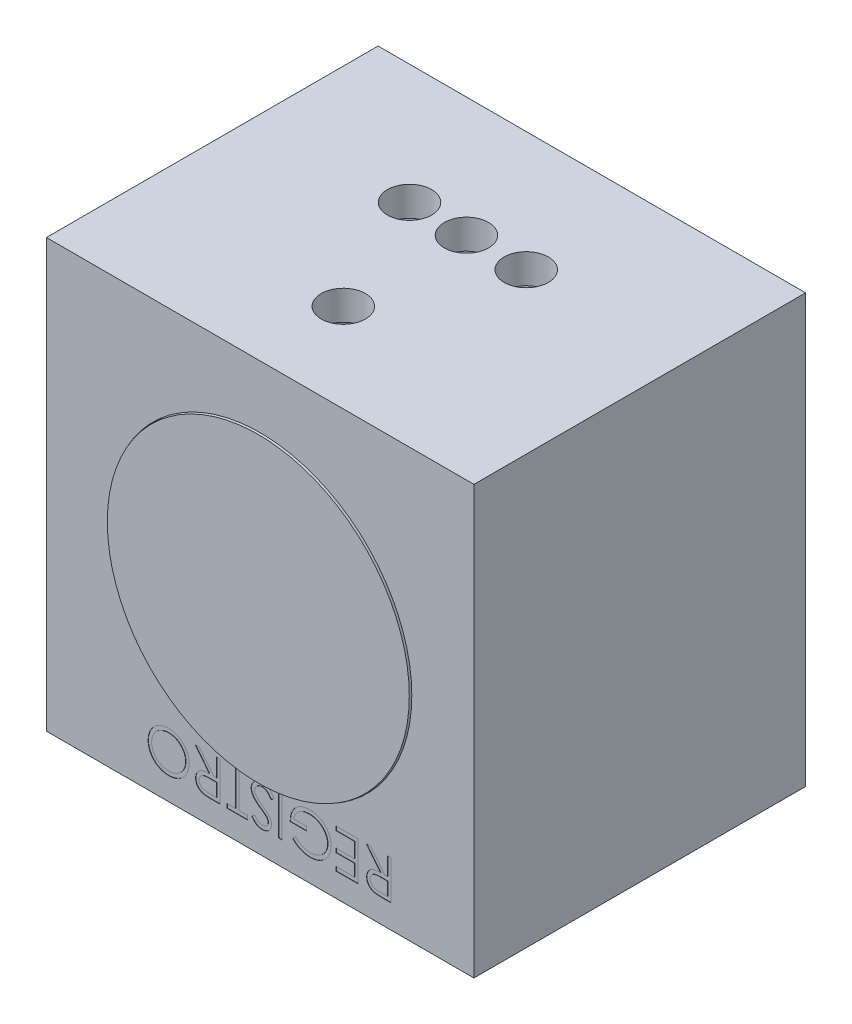
from build123d import *

# Parameters (mm, degrees)
CROQUIS1_W                   = 1160
CROQUIS1_H                   = 1160
CROQUIS1_W_2                 = 1000
CROQUIS1_H_2                 = 1000
SALIENTE_EXTRUIR2_DEPTH      = 900
CROQUIS2_W                   = 1160
CROQUIS2_H                   = 1160
SALIENTE_EXTRUIR3_DEPTH      = 80
CROQUIS5_R                   = 60
CORTAR_EXTRUIR2_DEPTH        = 1160
CROQUIS7_W                   = 1160
CROQUIS7_H                   = 1160
CROQUIS7_R                   = 387.5
SALIENTE_EXTRUIR5_DEPTH      = 100
CROQUIS8_W                   = 9.497863247
CROQUIS8_H                   = 105.833333333
CORTAR_EXTRUIR3_DEPTH        = 1
CROQUIS9_R                   = 411.5
CROQUIS9_R_2                 = 387.5
CORTAR_EXTRUIR4_DEPTH        = 75
CROQUIS10_R                  = 409.66856561
SALIENTE_EXTRUIR6_DEPTH      = 5
SALIENTE_EXTRUIR6_DEPTH_BACK = 75
CROQUIS11_W                  = 300
CROQUIS11_H                  = 300
CORTAR_EXTRUIR5_DEPTH        = 153


with BuildPart() as part:
    # Croquis1 → Saliente-Extruir2 (new body)
    with BuildSketch(Plane.XY):
        with Locations((170, -170)):
            Rectangle(CROQUIS1_W, CROQUIS1_H)
        with Locations((170, -170)):
            Rectangle(CROQUIS1_W_2, CROQUIS1_H_2, mode=Mode.SUBTRACT)
    extrude(amount=SALIENTE_EXTRUIR2_DEPTH)

    # Croquis2 → Saliente-Extruir3 (add)
    with BuildSketch(Plane(origin=(0, 0, 0), x_dir=(-1, 0, 0), z_dir=(0, 0, -1))):
        with Locations((-170, -170)):
            Rectangle(CROQUIS2_W, CROQUIS2_H)
    extrude(amount=-SALIENTE_EXTRUIR3_DEPTH)

    # Croquis5 → Cortar-Extruir2 (cut)
    with BuildSketch(Plane.XZ.offset(750)):
        with Locations((154.406796315, 324.689881119)):
            Circle(CROQUIS5_R)
        with Locations((0, 324.689881119)):
            Circle(CROQUIS5_R)
        with Locations((316.63824232, 324.689881119)):
            Circle(CROQUIS5_R)
        with Locations((154.406796315, 658.744524894)):
            Circle(CROQUIS5_R)
    extrude(amount=-CORTAR_EXTRUIR2_DEPTH, mode=Mode.SUBTRACT)

    # Croquis7 → Saliente-Extruir5 (add)
    with BuildSketch(Plane.XY.offset(900)):
        with Locations((170, -170)):
            Rectangle(CROQUIS7_W, CROQUIS7_H)
        with Locations((170, -170)):
            Circle(CROQUIS7_R, mode=Mode.SUBTRACT)
    extrude(amount=-SALIENTE_EXTRUIR5_DEPTH)

    # Croquis8 → Cortar-Extruir3 (cut)
    with BuildSketch(Plane.XY.offset(900)):
        with BuildLine():
            Line((525.486079703, -685.924081362), (504.306692684, -685.924081362))
            add(Edge.make_bspline(
                [(504.306692684, -685.924081362), (502.893329988, -685.919376738), (500.17951705, -685.910343339), (496.291706256, -685.859973841), (492.759077371, -685.715606419), (489.583477467, -685.59137068), (486.764964805, -685.364828645), (484.294896728, -685.148304316), (482.184649684, -684.864862668), (480.907215609, -684.601627259), (480.328828101, -684.482441405)],
                knots=[0, 0, 0, 0, 0.004240171, 0.008141597, 0.011663193, 0.014846742, 0.017674379, 0.020144679, 0.022285414, 0.024056647, 0.024056647, 0.024056647, 0.024056647], degree=3))
            add(Edge.make_bspline(
                [(480.328828101, -684.482441405), (479.554519524, -684.291153254), (478.022420475, -683.91265765), (475.816738569, -683.112262395), (473.714060024, -682.187517097), (471.722084902, -681.093073488), (469.841335178, -679.847412628), (468.072000343, -678.445526919), (466.437803695, -676.875405061), (464.880603033, -675.202087669), (463.520869409, -673.352720584), (462.296748432, -671.421154268), (461.269140813, -669.370201253), (460.460528295, -667.21020609), (459.782644745, -664.962357234), (459.327043712, -662.604442886), (459.043287418, -660.144134506), (459.015252283, -658.470114659), (459.001036968, -657.621296907)],
                knots=[0, 0, 0, 0, 0.002391253, 0.004731495, 0.007028312, 0.009276974, 0.011540776, 0.013788938, 0.016038399, 0.018334434, 0.020636821, 0.022913295, 0.02518878, 0.02750392, 0.029824972, 0.032224014, 0.034698677, 0.037244161, 0.037244161, 0.037244161, 0.037244161], degree=3))
            add(Edge.make_bspline(
                [(459.001036968, -657.621296907), (459.04545552, -656.211138549), (459.132127619, -653.459554354), (459.940259952, -649.466307511), (461.263919641, -645.741214396), (463.08819794, -642.289459048), (465.410269685, -639.176507007), (468.200871894, -636.451547476), (471.445753155, -634.150194997), (474.480707069, -632.571264362), (477.162898203, -631.555312717), (479.377526316, -630.83689693), (481.795145611, -630.291190729), (484.381071661, -629.79522004), (487.155278422, -629.41675456), (490.112179321, -629.147972139), (493.259169741, -628.975142998), (495.416348249, -628.94989192), (496.526077032, -628.936901875)],
                knots=[0, 0, 0, 0, 0.004226581, 0.008247153, 0.012163241, 0.016051685, 0.019914442, 0.023767412, 0.027703248, 0.031808998, 0.033990187, 0.036303384, 0.038787112, 0.041419146, 0.044201516, 0.047182367, 0.050324635, 0.053653735, 0.053653735, 0.053653735, 0.053653735], degree=3))
            Line((496.526077032, -628.936901875), (457.644199361, -580.090748029))
            Line((457.644199361, -580.090748029), (469.389324895, -580.090748029))
            Line((469.389324895, -580.090748029), (508.271202566, -628.936901875))
            Line((508.271202566, -628.936901875), (515.988216455, -628.936901875))
            Line((515.988216455, -628.936901875), (515.988216455, -580.090748029))
            Line((515.988216455, -580.090748029), (525.486079703, -580.090748029))
            Line((525.486079703, -580.090748029), (525.486079703, -685.924081362))
        make_face()
        with BuildLine():
            Line((515.988216455, -675.069380507), (515.988216455, -639.791602729))
            Line((515.988216455, -639.791602729), (496.610879383, -639.643198616))
            add(Edge.make_bspline(
                [(496.610879383, -639.643198616), (495.706154282, -639.642798135), (493.952539357, -639.642021888), (491.415544608, -639.762789185), (489.053335976, -639.90015989), (486.874978387, -640.110330187), (484.879400754, -640.381028666), (483.067921179, -640.720164141), (481.436536541, -641.113600045), (479.53992333, -641.72876744), (477.397695585, -642.661364726), (475.117582325, -644.107437868), (473.123688584, -645.856250201), (471.465986076, -647.881281041), (470.134517542, -650.11733359), (469.209694041, -652.513802674), (468.600240744, -655.032929569), (468.533069857, -656.762612597), (468.498900216, -657.642497494)],
                knots=[0, 0, 0, 0, 0.002713758, 0.005260036, 0.007617976, 0.009811904, 0.011823727, 0.013657424, 0.015338833, 0.016854045, 0.019635203, 0.022322999, 0.024921693, 0.027557482, 0.03014265, 0.032693777, 0.035239437, 0.037875225, 0.037875225, 0.037875225, 0.037875225], degree=3))
            add(Edge.make_bspline(
                [(468.498900216, -657.642497494), (468.534799992, -658.493762716), (468.605940249, -660.180659767), (469.199990229, -662.644675468), (470.16997976, -664.987631001), (471.497646476, -667.177285777), (473.150070085, -669.150195646), (475.074771428, -670.83309059), (477.226458015, -672.231191743), (479.221211484, -673.153662281), (481.017192106, -673.696445382), (482.569360146, -674.090451043), (484.3384683, -674.366394751), (486.303694402, -674.620189246), (488.473671542, -674.835114294), (490.849722096, -674.977770956), (493.430147177, -675.063037078), (495.218637226, -675.067216822), (496.144466455, -675.069380507)],
                knots=[0, 0, 0, 0, 0.002551216, 0.005055579, 0.00755563, 0.010133486, 0.012706804, 0.015245657, 0.017774222, 0.020383273, 0.021804819, 0.023398816, 0.025183321, 0.027171321, 0.029344149, 0.031723248, 0.034311109, 0.037088467, 0.037088467, 0.037088467, 0.037088467], degree=3))
            Line((496.144466455, -675.069380507), (515.988216455, -675.069380507))
        make_face(mode=Mode.SUBTRACT)
        Polygon((435.934797652, -685.924081362), (376.233942951, -685.924081362), (376.233942951, -675.069380507), (426.436934404, -675.069380507), (426.436934404, -642.505277943), (376.233942951, -642.505277943), (376.233942951, -631.650577088), (426.436934404, -631.650577088), (426.436934404, -590.945448883), (376.233942951, -590.945448883), (376.233942951, -580.090748029), (435.934797652, -580.090748029), align=None)
        with BuildLine():
            Line((258.189071156, -667.861180721), (266.330096797, -660.144166832))
            add(Edge.make_bspline(
                [(266.330096797, -660.144166832), (267.811889366, -661.528101813), (270.732273835, -664.255624078), (275.470730633, -667.834010378), (280.421413261, -670.875536542), (285.544072375, -673.374382104), (290.739923824, -675.316822662), (295.905232342, -676.721309625), (301.003784165, -677.624566268), (304.388656603, -677.730666722), (306.059997972, -677.783055721)],
                knots=[0, 0, 0, 0, 0.006079543, 0.011981842, 0.017777712, 0.023485672, 0.029053804, 0.034392186, 0.039529601, 0.044540524, 0.044540524, 0.044540524, 0.044540524], degree=3))
            add(Edge.make_bspline(
                [(306.059997972, -677.783055721), (307.085508143, -677.770530596), (309.133868779, -677.745512832), (312.176570371, -677.426950733), (315.186954236, -676.967362203), (318.15463914, -676.309227078), (321.091424254, -675.454420824), (323.990776373, -674.422369772), (326.847099735, -673.18000044), (329.645367894, -671.76358569), (332.372025112, -670.217335945), (334.936460725, -668.492809632), (337.349368752, -666.643075514), (339.59368623, -664.643874775), (341.700155295, -662.528481738), (343.630215997, -660.266839193), (345.426075984, -657.892421527), (347.020563911, -655.371193195), (348.461745695, -652.77479069), (349.709686344, -650.123910747), (350.784235539, -647.437249464), (351.642865939, -644.713292335), (352.333171915, -641.953778724), (352.821779469, -639.163020123), (353.096217065, -636.327266492), (353.1437887, -634.42840978), (353.167703635, -633.473827623)],
                knots=[0, 0, 0, 0, 0.003075255, 0.006142534, 0.009167984, 0.012207959, 0.015254064, 0.018338731, 0.021434308, 0.024591558, 0.027744464, 0.030831462, 0.033854907, 0.036858514, 0.039841777, 0.042803568, 0.04577165, 0.04876514, 0.051744785, 0.054675224, 0.057549136, 0.060418822, 0.063236586, 0.066077228, 0.068910343, 0.071774385, 0.071774385, 0.071774385, 0.071774385], degree=3))
            add(Edge.make_bspline(
                [(353.167703635, -633.473827623), (353.144633657, -632.498079018), (353.098556697, -630.549246254), (352.80970986, -627.639633104), (352.255567643, -624.779164488), (351.578689621, -621.940854931), (350.620587266, -619.160931687), (349.506823089, -616.398683798), (348.163873198, -613.67978297), (346.61743641, -611.023181173), (344.908457759, -608.437895507), (343.0291885, -605.982164661), (340.976079336, -603.684688047), (338.786877748, -601.511875593), (336.441609964, -599.477448523), (333.917529705, -597.605926464), (331.249967404, -595.868370567), (328.437740237, -594.283869099), (325.510572272, -592.868503471), (322.50924685, -591.609866642), (319.424117446, -590.573327311), (316.271413005, -589.72853158), (313.054887695, -589.036070397), (309.758215617, -588.590588203), (306.405636088, -588.267317854), (304.145682215, -588.243681638), (303.007113357, -588.23177367)],
                knots=[0, 0, 0, 0, 0.002927601, 0.005847207, 0.008757948, 0.011663125, 0.014592875, 0.017569198, 0.020593758, 0.023680974, 0.026785612, 0.029885323, 0.03294879, 0.036021998, 0.039133288, 0.042254026, 0.045441173, 0.048678274, 0.051930544, 0.055190543, 0.058435411, 0.061685676, 0.064978804, 0.06829783, 0.071660647, 0.075074995, 0.075074995, 0.075074995, 0.075074995], degree=3))
            add(Edge.make_bspline(
                [(303.007113357, -588.23177367), (301.634952978, -588.260444912), (298.940493144, -588.316745555), (294.979791987, -588.755375525), (291.175457766, -589.439556706), (287.53987707, -590.444642952), (284.059849638, -591.716831285), (280.748233225, -593.290085199), (277.595799269, -595.1477991), (274.616506233, -597.252549553), (271.880029646, -599.597022027), (269.392726818, -602.106408523), (267.227484315, -604.800731605), (265.370181296, -607.679404894), (263.771578188, -610.700040933), (262.496393476, -613.914412896), (261.510099602, -617.286617947), (261.106618778, -619.617911087), (260.90274637, -620.795876234)],
                knots=[0, 0, 0, 0, 0.004115591, 0.008081631, 0.011940487, 0.015700231, 0.019382608, 0.023043134, 0.026682788, 0.030347547, 0.033971608, 0.037479648, 0.040933002, 0.044320124, 0.047743477, 0.051168537, 0.054677666, 0.058261757, 0.058261757, 0.058261757, 0.058261757], degree=3))
            Line((260.90274637, -620.795876234), (296.180524148, -620.795876234))
            Line((296.180524148, -620.795876234), (296.180524148, -631.650577088))
            Line((296.180524148, -631.650577088), (251.404883122, -631.650577088))
            add(Edge.make_bspline(
                [(251.404883122, -631.650577088), (251.456464728, -629.627422069), (251.557419248, -625.667742235), (252.26556265, -619.893164998), (253.409061949, -614.439068557), (254.971171379, -609.299709009), (256.993352474, -604.482369419), (259.453902739, -599.982158705), (262.39220259, -595.828149545), (265.70358975, -591.986429674), (269.419850379, -588.559570163), (273.440568173, -585.547676325), (277.772386026, -583.010621052), (282.411206395, -580.946548641), (287.341843311, -579.335644509), (292.575706223, -578.193503976), (298.105697482, -577.509216989), (301.895639855, -577.421787183), (303.833936274, -577.377072815)],
                knots=[0, 0, 0, 0, 0.006068703, 0.011877548, 0.017424328, 0.022769105, 0.027966536, 0.033071302, 0.038123718, 0.04320346, 0.048259211, 0.053258326, 0.058247, 0.063286233, 0.068461956, 0.073780769, 0.079334514, 0.085148154, 0.085148154, 0.085148154, 0.085148154], degree=3))
            add(Edge.make_bspline(
                [(303.833936274, -577.377072815), (305.02864751, -577.394281957), (307.385003116, -577.428223931), (310.86513356, -577.669443723), (314.24930923, -578.040784958), (317.537037118, -578.601554168), (320.740410798, -579.288402044), (323.84343158, -580.167929017), (326.857919971, -581.186006354), (329.788535251, -582.343994576), (332.608677499, -583.685708956), (335.330907893, -585.176738531), (337.970274076, -586.809394915), (340.508797398, -588.611913346), (342.959704524, -590.570811546), (345.307191985, -592.690015763), (347.564401631, -594.963047241), (348.978348981, -596.577126817), (349.690807267, -597.390427516)],
                knots=[0, 0, 0, 0, 0.003583903, 0.007068611, 0.010461037, 0.013793038, 0.017069883, 0.020284902, 0.023462728, 0.026612211, 0.029732228, 0.03282519, 0.035919677, 0.039037317, 0.042159567, 0.04532698, 0.048520115, 0.051763182, 0.051763182, 0.051763182, 0.051763182], degree=3))
            add(Edge.make_bspline(
                [(349.690807267, -597.390427516), (350.724524733, -598.680706785), (352.77480102, -601.239848019), (355.413926232, -605.340132052), (357.663682936, -609.585616872), (359.489090891, -613.98812111), (360.914456836, -618.543526832), (361.936693526, -623.246013019), (362.535628223, -628.101635181), (362.62191376, -631.387465803), (362.665566883, -633.04981587)],
                knots=[0, 0, 0, 0, 0.004957221, 0.009832158, 0.014602338, 0.019354533, 0.02410862, 0.028903188, 0.033773236, 0.038759883, 0.038759883, 0.038759883, 0.038759883], degree=3))
            add(Edge.make_bspline(
                [(362.665566883, -633.04981587), (362.649429411, -634.294591853), (362.617359565, -636.768323477), (362.230181871, -640.441153627), (361.671358401, -644.04785915), (360.861924115, -647.591779515), (359.796911474, -651.057181294), (358.517872242, -654.470692383), (357.019753523, -657.818669229), (355.271503902, -661.07143778), (353.368554441, -664.227885676), (351.228717792, -667.188663076), (348.970865635, -670.011019079), (346.486826934, -672.61504735), (343.869684279, -675.083936112), (341.054340036, -677.352613042), (338.08698403, -679.459354894), (334.943655946, -681.362936234), (331.674215114, -683.073449622), (328.285698165, -684.572896211), (324.779355475, -685.812163525), (321.181398158, -686.863653693), (317.464607783, -687.641231294), (313.655952066, -688.205133632), (309.735579685, -688.590989914), (307.085633076, -688.622021928), (305.741989158, -688.637756576)],
                knots=[0, 0, 0, 0, 0.003732809, 0.007418176, 0.011067449, 0.014677779, 0.018312676, 0.021935434, 0.025607789, 0.029306669, 0.0330081, 0.036655587, 0.040258002, 0.043842407, 0.047442264, 0.05104468, 0.054679885, 0.05835218, 0.062059919, 0.06574303, 0.069458036, 0.073208862, 0.076980244, 0.080839042, 0.084756564, 0.08878607, 0.08878607, 0.08878607, 0.08878607], degree=3))
            add(Edge.make_bspline(
                [(305.741989158, -688.637756576), (304.64620568, -688.620277642), (302.47339581, -688.585618972), (299.240282635, -688.344142298), (296.063508203, -687.965645821), (292.927136577, -687.436381881), (289.843109751, -686.736251507), (286.802084079, -685.882995171), (283.80981119, -684.895089212), (280.869850857, -683.71597081), (277.962214665, -682.377871837), (275.070795101, -680.871596077), (272.205455234, -679.171462561), (269.361230532, -677.27240229), (266.520184293, -675.207037311), (263.727253457, -672.916295186), (260.915021567, -670.490511876), (259.106728614, -668.746312502), (258.189071156, -667.861180721)],
                knots=[0, 0, 0, 0, 0.003287185, 0.006518102, 0.009721005, 0.012882239, 0.016055607, 0.019203662, 0.022354643, 0.025504125, 0.028700988, 0.031953534, 0.035280406, 0.038690802, 0.042210355, 0.045812771, 0.049524327, 0.053348493, 0.053348493, 0.053348493, 0.053348493], degree=3))
        make_face()
        with Locations((224.946549789, -633.007414696)):
            Rectangle(CROQUIS8_W, CROQUIS8_H)
        with BuildLine():
            Line((207.986079703, -600.506913894), (199.039431733, -605.870662558))
            add(Edge.make_bspline(
                [(199.039431733, -605.870662558), (198.207332654, -604.477763299), (196.61306293, -601.809022072), (193.953581356, -598.202886087), (191.197895709, -595.137887538), (188.325599194, -592.631856786), (185.354224096, -590.658854734), (182.264372948, -589.261787251), (179.066458195, -588.390447044), (176.890106927, -588.284611093), (175.803587716, -588.23177367)],
                knots=[0, 0, 0, 0, 0.004865339, 0.009321801, 0.013419003, 0.01720638, 0.020728614, 0.024078105, 0.027343409, 0.030598786, 0.030598786, 0.030598786, 0.030598786], degree=3))
            add(Edge.make_bspline(
                [(175.803587716, -588.23177367), (174.875863264, -588.258232139), (173.036647358, -588.310686117), (170.323720144, -588.794338913), (167.702101903, -589.585591322), (165.197884974, -590.65822876), (162.877298749, -591.976700963), (160.810053107, -593.531540475), (159.063374011, -595.327700462), (157.619344145, -597.300418822), (156.488933668, -599.408516846), (155.684619684, -601.600077755), (155.167945812, -603.861136324), (155.102438969, -605.394440228), (155.069413036, -606.167470785)],
                knots=[0, 0, 0, 0, 0.002781239, 0.005513813, 0.008236913, 0.010981714, 0.013669176, 0.016226023, 0.018714722, 0.02115721, 0.023537915, 0.025865446, 0.028144287, 0.030461367, 0.030461367, 0.030461367, 0.030461367], degree=3))
            add(Edge.make_bspline(
                [(155.069413036, -606.167470785), (155.113035894, -607.04892868), (155.201376938, -608.833977036), (155.979932421, -611.472112262), (157.168754061, -614.094125895), (158.286112798, -615.716315728), (158.864318218, -616.555758712)],
                knots=[0, 0, 0, 0, 0.002639196, 0.005344661, 0.008190598, 0.011242672, 0.011242672, 0.011242672, 0.011242672], degree=3))
            add(Edge.make_bspline(
                [(158.864318218, -616.555758712), (159.336756638, -617.163252467), (160.33149338, -618.44235326), (162.066775054, -620.312903352), (164.039899648, -622.293470676), (166.301952077, -624.344523433), (168.819946766, -626.508017518), (171.622430679, -628.743828329), (174.676680451, -631.085302083), (176.830931772, -632.631778168), (177.944847064, -633.431426447)],
                knots=[0, 0, 0, 0, 0.00230775, 0.004859054, 0.007647394, 0.010693573, 0.014016389, 0.017605492, 0.021447189, 0.025560594, 0.025560594, 0.025560594, 0.025560594], degree=3))
            add(Edge.make_bspline(
                [(177.944847064, -633.431426447), (179.05818604, -634.224710508), (181.186805383, -635.741409225), (184.165925542, -637.989510977), (186.826343009, -640.05801298), (189.181613933, -641.918101762), (191.170804472, -643.650904975), (192.866633873, -645.163554049), (194.206536572, -646.536822722), (194.952160819, -647.42697086), (195.286927727, -647.826625432)],
                knots=[0, 0, 0, 0, 0.004100985, 0.007840771, 0.011195157, 0.014211457, 0.016842125, 0.019108209, 0.021027301, 0.022590979, 0.022590979, 0.022590979, 0.022590979], degree=3))
            add(Edge.make_bspline(
                [(195.286927727, -647.826625432), (195.754709604, -648.44959247), (196.674665447, -649.674740756), (197.890326399, -651.589123182), (198.91549659, -653.545076969), (199.740566926, -655.549690927), (200.407770048, -657.587899189), (200.871647378, -659.675003822), (201.157571558, -661.796836313), (201.187106708, -663.22443322), (201.201891669, -663.939072014)],
                knots=[0, 0, 0, 0, 0.002336493, 0.004595028, 0.006794991, 0.008952561, 0.0110913, 0.013220666, 0.015358565, 0.017501503, 0.017501503, 0.017501503, 0.017501503], degree=3))
            add(Edge.make_bspline(
                [(201.201891669, -663.939072014), (201.162598549, -665.058877802), (201.084852172, -667.274554318), (200.421913284, -670.509570826), (199.387907099, -673.607721981), (197.891937173, -676.500054143), (196.044134434, -679.182467214), (193.850789067, -681.6073775), (191.270825921, -683.691316603), (188.398668072, -685.462831426), (185.291585245, -686.876105134), (182.02622342, -687.905904903), (178.617255381, -688.50943043), (176.300635073, -688.594560898), (175.125168912, -688.637756576)],
                knots=[0, 0, 0, 0, 0.003356395, 0.00664105, 0.00986584, 0.013127493, 0.016373677, 0.019615218, 0.022899873, 0.026288785, 0.029713713, 0.033113286, 0.036536048, 0.040061726, 0.040061726, 0.040061726, 0.040061726], degree=3))
            add(Edge.make_bspline(
                [(175.125168912, -688.637756576), (173.877640459, -688.596127778), (171.403642362, -688.513572895), (167.763443675, -687.751633238), (164.237747059, -686.567777936), (161.412177918, -685.15782909), (159.199940309, -683.764801877), (157.514645364, -682.492759043), (155.797530916, -681.031490589), (154.067098198, -679.350040065), (152.306250118, -677.4820826), (150.523101726, -675.411792592), (148.700964582, -673.157830591), (147.529127064, -671.548354218), (146.928387395, -670.723260048)],
                knots=[0, 0, 0, 0, 0.003738584, 0.007414059, 0.011108136, 0.014872181, 0.016854294, 0.018944676, 0.021200522, 0.023614505, 0.026179075, 0.02889945, 0.031809805, 0.034871217, 0.034871217, 0.034871217, 0.034871217], degree=3))
            Line((146.928387395, -670.723260048), (155.514625376, -664.214679652))
            add(Edge.make_bspline(
                [(155.514625376, -664.214679652), (156.03304791, -664.88263825), (157.0314085, -666.168970335), (158.547731584, -667.969779012), (159.974736593, -669.616972953), (161.391441643, -671.043922803), (162.688642537, -672.357500017), (163.970026995, -673.46213814), (165.186093265, -674.392906027), (166.715431988, -675.387511114), (168.65769649, -676.349798884), (171.073085707, -677.177136991), (173.598901948, -677.685585331), (175.313622828, -677.750208441), (176.185198293, -677.783055721)],
                knots=[0, 0, 0, 0, 0.002536285, 0.004884292, 0.007062182, 0.00907121, 0.010915174, 0.012598452, 0.014141878, 0.015506149, 0.01806607, 0.020620455, 0.023148398, 0.02576158, 0.02576158, 0.02576158, 0.02576158], degree=3))
            add(Edge.make_bspline(
                [(176.185198293, -677.783055721), (177.278760666, -677.747016174), (179.387592686, -677.677517304), (182.374541702, -676.898512192), (185.078475941, -675.71408741), (187.396173185, -674.006159222), (189.309859855, -671.969979852), (190.71132591, -669.647860682), (191.549237831, -667.083170417), (191.651796791, -665.294980653), (191.704028421, -664.384284353)],
                knots=[0, 0, 0, 0, 0.003273209, 0.006312075, 0.009196601, 0.012080193, 0.014885488, 0.017528769, 0.020156958, 0.022884593, 0.022884593, 0.022884593, 0.022884593], degree=3))
            add(Edge.make_bspline(
                [(191.704028421, -664.384284353), (191.690900187, -663.817554383), (191.664460839, -662.676199665), (191.34923957, -660.993392319), (190.878837919, -659.330395505), (190.212056577, -657.677627928), (189.305892844, -655.98800368), (188.075163405, -654.27115329), (186.535068475, -652.484108474), (185.353086158, -651.322957883), (184.729035098, -650.709905347)],
                knots=[0, 0, 0, 0, 0.001698166, 0.003419988, 0.005117756, 0.006877533, 0.00875567, 0.010855492, 0.013201009, 0.015824491, 0.015824491, 0.015824491, 0.015824491], degree=3))
            add(Edge.make_bspline(
                [(184.729035098, -650.709905347), (184.49736979, -650.503166709), (183.946986045, -650.012003029), (182.940785434, -649.207903114), (181.612038916, -648.216009761), (179.995443785, -646.98872662), (178.061192609, -645.565072885), (175.809072697, -643.963251755), (173.264188252, -642.131262876), (171.458311271, -640.850451529), (170.503440814, -640.173213306)],
                knots=[0, 0, 0, 0, 0.000931379, 0.002212744, 0.003862171, 0.005905912, 0.008301673, 0.011066867, 0.014196809, 0.017708755, 0.017708755, 0.017708755, 0.017708755], degree=3))
            add(Edge.make_bspline(
                [(170.503440814, -640.173213306), (169.354819961, -639.337390653), (167.130674875, -637.718935926), (163.966018045, -635.287326922), (161.096647575, -632.909140855), (158.512277005, -630.599719365), (156.188085627, -628.37606393), (154.147502646, -626.213145946), (152.381269443, -624.125149532), (150.453825155, -621.466411963), (148.507677788, -618.170809421), (146.839016375, -614.131254657), (145.777442556, -610.080107633), (145.639573404, -607.360768431), (145.571549789, -606.019066672)],
                knots=[0, 0, 0, 0, 0.004261529, 0.00825186, 0.011970676, 0.015439094, 0.018647746, 0.021617342, 0.024356241, 0.026845483, 0.031463319, 0.035798049, 0.039926996, 0.043948239, 0.043948239, 0.043948239, 0.043948239], degree=3))
            add(Edge.make_bspline(
                [(145.571549789, -606.019066672), (145.591451694, -605.070262215), (145.630869023, -603.191078443), (146.082803414, -600.431443748), (146.747305053, -597.752363395), (147.737664813, -595.18717733), (148.975643267, -592.707296349), (150.482872146, -590.31706861), (152.309461924, -588.055768122), (154.338584026, -585.879479791), (156.592425285, -583.911242163), (158.977449523, -582.158163831), (161.480270148, -580.657139032), (164.129468914, -579.477900622), (166.881406311, -578.534610725), (169.749000154, -577.858485352), (172.738412321, -577.442105554), (174.770456269, -577.398992398), (175.803587716, -577.377072815)],
                knots=[0, 0, 0, 0, 0.002843725, 0.005632227, 0.00836776, 0.011112151, 0.013861697, 0.016673074, 0.019570194, 0.022569759, 0.025589262, 0.028532099, 0.031440832, 0.034325359, 0.037214945, 0.040156331, 0.043151622, 0.04624952, 0.04624952, 0.04624952, 0.04624952], degree=3))
            add(Edge.make_bspline(
                [(175.803587716, -577.377072815), (176.602906854, -577.392707088), (178.19147853, -577.423778735), (180.534861318, -577.691964353), (182.835212336, -578.085261961), (185.063648613, -578.684897835), (187.247915621, -579.429552191), (189.368553165, -580.341266864), (191.430676823, -581.42664251), (193.436833906, -582.687357988), (195.405386427, -584.140666909), (197.328389561, -585.818665219), (199.215469796, -587.713320988), (201.074465838, -589.821997617), (202.861586691, -592.179550036), (204.621773099, -594.748590225), (206.345859699, -597.537417791), (207.429127747, -599.498593876), (207.986079703, -600.506913894)],
                knots=[0, 0, 0, 0, 0.002397167, 0.004764144, 0.007068093, 0.009392435, 0.011678661, 0.013986411, 0.016309786, 0.01866267, 0.021088076, 0.023642901, 0.026311313, 0.029105451, 0.032069441, 0.035180226, 0.038445529, 0.0419009, 0.0419009, 0.0419009, 0.0419009], degree=3))
        make_face()
        Polygon((136.073686541, -675.069380507), (136.073686541, -685.924081362), (80.44334466, -685.924081362), (80.44334466, -675.069380507), (103.509583977, -675.069380507), (103.509583977, -580.090748029), (113.007447224, -580.090748029), (113.007447224, -675.069380507), align=None)
        with BuildLine():
            Line((61.447618165, -685.924081362), (40.268231145, -685.924081362))
            add(Edge.make_bspline(
                [(40.268231145, -685.924081362), (38.85486845, -685.919376738), (36.141055512, -685.910343339), (32.253244718, -685.859973841), (28.720615832, -685.715606419), (25.545015929, -685.59137068), (22.726503267, -685.364828645), (20.256435189, -685.148304316), (18.146188146, -684.864862668), (16.868754071, -684.601627259), (16.290366562, -684.482441405)],
                knots=[0, 0, 0, 0, 0.004240171, 0.008141597, 0.011663193, 0.014846742, 0.017674379, 0.020144679, 0.022285414, 0.024056647, 0.024056647, 0.024056647, 0.024056647], degree=3))
            add(Edge.make_bspline(
                [(16.290366562, -684.482441405), (15.516057986, -684.291153254), (13.983958937, -683.91265765), (11.778277031, -683.112262395), (9.675598485, -682.187517097), (7.683623364, -681.093073488), (5.80287364, -679.847412628), (4.033538805, -678.445526919), (2.399342157, -676.875405061), (0.842141495, -675.202087669), (-0.517592129, -673.352720584), (-1.741713107, -671.421154268), (-2.769320725, -669.370201253), (-3.577933243, -667.21020609), (-4.255816794, -664.962357234), (-4.711417826, -662.604442886), (-4.995174121, -660.144134506), (-5.023209255, -658.470114659), (-5.03742457, -657.621296907)],
                knots=[0, 0, 0, 0, 0.002391253, 0.004731495, 0.007028312, 0.009276974, 0.011540776, 0.013788938, 0.016038399, 0.018334434, 0.020636821, 0.022913295, 0.02518878, 0.02750392, 0.029824972, 0.032224014, 0.034698677, 0.037244161, 0.037244161, 0.037244161, 0.037244161], degree=3))
            add(Edge.make_bspline(
                [(-5.03742457, -657.621296907), (-4.993006018, -656.211138549), (-4.906333919, -653.459554354), (-4.098201586, -649.466307511), (-2.774541898, -645.741214396), (-0.950263599, -642.289459048), (1.371808147, -639.176507007), (4.162410356, -636.451547476), (7.407291617, -634.150194997), (10.442245531, -632.571264362), (13.124436664, -631.555312717), (15.339064778, -630.83689693), (17.756684072, -630.291190729), (20.342610123, -629.79522004), (23.116816884, -629.41675456), (26.073717783, -629.147972139), (29.220708203, -628.975142998), (31.37788671, -628.94989192), (32.487615494, -628.936901875)],
                knots=[0, 0, 0, 0, 0.004226581, 0.008247153, 0.012163241, 0.016051685, 0.019914442, 0.023767412, 0.027703248, 0.031808998, 0.033990187, 0.036303384, 0.038787112, 0.041419146, 0.044201516, 0.047182367, 0.050324635, 0.053653735, 0.053653735, 0.053653735, 0.053653735], degree=3))
            Line((32.487615494, -628.936901875), (-6.394262177, -580.090748029))
            Line((-6.394262177, -580.090748029), (5.350863357, -580.090748029))
            Line((5.350863357, -580.090748029), (44.232741028, -628.936901875))
            Line((44.232741028, -628.936901875), (51.949754917, -628.936901875))
            Line((51.949754917, -628.936901875), (51.949754917, -580.090748029))
            Line((51.949754917, -580.090748029), (61.447618165, -580.090748029))
            Line((61.447618165, -580.090748029), (61.447618165, -685.924081362))
        make_face()
        with BuildLine():
            Line((51.949754917, -675.069380507), (51.949754917, -639.791602729))
            Line((51.949754917, -639.791602729), (32.572417844, -639.643198616))
            add(Edge.make_bspline(
                [(32.572417844, -639.643198616), (31.667692743, -639.642798135), (29.914077819, -639.642021888), (27.37708307, -639.762789185), (25.014874438, -639.90015989), (22.836516848, -640.110330187), (20.840939215, -640.381028666), (19.02945964, -640.720164141), (17.398075002, -641.113600045), (15.501461791, -641.72876744), (13.359234046, -642.661364726), (11.079120786, -644.107437868), (9.085227045, -645.856250201), (7.427524538, -647.881281041), (6.096056004, -650.11733359), (5.171232502, -652.513802674), (4.561779205, -655.032929569), (4.494608319, -656.762612597), (4.460438677, -657.642497494)],
                knots=[0, 0, 0, 0, 0.002713758, 0.005260036, 0.007617976, 0.009811904, 0.011823727, 0.013657424, 0.015338833, 0.016854045, 0.019635203, 0.022322999, 0.024921693, 0.027557482, 0.03014265, 0.032693777, 0.035239437, 0.037875225, 0.037875225, 0.037875225, 0.037875225], degree=3))
            add(Edge.make_bspline(
                [(4.460438677, -657.642497494), (4.496338454, -658.493762716), (4.567478711, -660.180659767), (5.16152869, -662.644675468), (6.131518222, -664.987631001), (7.459184938, -667.177285777), (9.111608547, -669.150195646), (11.03630989, -670.83309059), (13.187996476, -672.231191743), (15.182749945, -673.153662281), (16.978730568, -673.696445382), (18.530898608, -674.090451043), (20.300006761, -674.366394751), (22.265232864, -674.620189246), (24.435210004, -674.835114294), (26.811260558, -674.977770956), (29.391685639, -675.063037078), (31.180175687, -675.067216822), (32.106004917, -675.069380507)],
                knots=[0, 0, 0, 0, 0.002551216, 0.005055579, 0.00755563, 0.010133486, 0.012706804, 0.015245657, 0.017774222, 0.020383273, 0.021804819, 0.023398816, 0.025183321, 0.027171321, 0.029344149, 0.031723248, 0.034311109, 0.037088467, 0.037088467, 0.037088467, 0.037088467], degree=3))
            Line((32.106004917, -675.069380507), (51.949754917, -675.069380507))
        make_face(mode=Mode.SUBTRACT)
        with BuildLine():
            add(Edge.make_bspline(
                [(-77.628236536, -688.637756576), (-79.588123488, -688.588956498), (-83.43750316, -688.49310912), (-89.089659525, -687.735204157), (-94.501826901, -686.487737693), (-99.677237801, -684.726168208), (-104.595763864, -682.442084825), (-109.272955345, -679.669156343), (-113.692735456, -676.380130329), (-117.84367275, -672.653082569), (-121.616473364, -668.556278376), (-124.899421285, -664.158070478), (-127.693516134, -659.546982485), (-129.976391523, -654.692985388), (-131.770196068, -649.617750787), (-133.007311621, -644.291044455), (-133.797733701, -638.748238872), (-133.890127128, -634.967659183), (-133.93699722, -633.04981587)],
                knots=[0, 0, 0, 0, 0.005878071, 0.011545016, 0.017073331, 0.022517302, 0.027914507, 0.033313835, 0.038800652, 0.044415326, 0.050027118, 0.055479916, 0.060853753, 0.066174129, 0.071544912, 0.076970026, 0.082555767, 0.088306756, 0.088306756, 0.088306756, 0.088306756], degree=3))
            add(Edge.make_bspline(
                [(-133.93699722, -633.04981587), (-133.890111431, -631.146110839), (-133.79769411, -627.393687675), (-133.00666938, -621.885898917), (-131.764679155, -616.591922793), (-129.99858255, -611.524072375), (-127.714025601, -606.679859378), (-124.915534217, -602.065545153), (-121.639962105, -597.654512585), (-117.882630119, -593.537765431), (-113.779592894, -589.764616799), (-109.408558297, -586.429096676), (-104.774800828, -583.650417161), (-99.95064212, -581.333414772), (-94.888071071, -579.57859498), (-89.622792686, -578.299825962), (-84.124952427, -577.517369766), (-80.379819004, -577.424351637), (-78.47626004, -577.377072815)],
                knots=[0, 0, 0, 0, 0.00570863, 0.011252371, 0.016656857, 0.022000625, 0.027321001, 0.032694838, 0.038164631, 0.043777784, 0.049389576, 0.054867867, 0.060241704, 0.065571153, 0.070894908, 0.076283737, 0.08180648, 0.087515109, 0.087515109, 0.087515109, 0.087515109], degree=3))
            add(Edge.make_bspline(
                [(-78.47626004, -577.377072815), (-76.558425693, -577.423917035), (-72.777863676, -577.516259463), (-67.228107092, -578.308025428), (-61.8976067, -579.54568187), (-56.802775035, -581.316105168), (-51.941940184, -583.595555697), (-47.315572262, -586.396661888), (-42.918111959, -589.697380827), (-38.794308533, -593.451762161), (-35.025709667, -597.546931566), (-31.711009349, -601.912226917), (-28.926052128, -606.506131755), (-26.64563934, -611.309709133), (-24.841919653, -616.310542633), (-23.610969495, -621.540089368), (-22.814651391, -626.969045319), (-22.722879167, -630.665434524), (-22.676313459, -632.541001768)],
                knots=[0, 0, 0, 0, 0.005750989, 0.01133673, 0.016782476, 0.022146267, 0.027485827, 0.032859664, 0.038342137, 0.043955291, 0.049567083, 0.055015675, 0.060371373, 0.065653426, 0.070944279, 0.076286911, 0.08174667, 0.087370583, 0.087370583, 0.087370583, 0.087370583], degree=3))
            add(Edge.make_bspline(
                [(-22.676313459, -632.541001768), (-22.692464994, -633.799900136), (-22.724564306, -636.301815305), (-23.111578835, -640.016982606), (-23.672031861, -643.67280311), (-24.479450393, -647.256987717), (-25.520951805, -650.770121717), (-26.804425611, -654.205020554), (-28.275287086, -657.589977702), (-30.026550846, -660.860571423), (-31.937232019, -664.021935144), (-34.020637866, -667.034538646), (-36.291294859, -669.844568692), (-38.7167672, -672.49717796), (-41.330628861, -674.947092441), (-44.093541304, -677.247725915), (-47.019961341, -679.375263071), (-50.114517177, -681.285019772), (-53.29831194, -683.039154502), (-56.594444213, -684.503712649), (-59.933368922, -685.798185645), (-63.344496621, -686.826907812), (-66.819936813, -687.645571044), (-70.364034176, -688.20183202), (-73.973138335, -688.589706486), (-76.404628463, -688.621670967), (-77.628236536, -688.637756576)],
                knots=[0, 0, 0, 0, 0.003775193, 0.00750276, 0.011193916, 0.014866272, 0.01851536, 0.02217785, 0.02586096, 0.029578566, 0.033298107, 0.036938501, 0.040557411, 0.044128436, 0.04771284, 0.051295928, 0.054908996, 0.058556298, 0.062199161, 0.065804819, 0.069368095, 0.072935972, 0.076484332, 0.080070805, 0.083692881, 0.087362114, 0.087362114, 0.087362114, 0.087362114], degree=3))
        make_face()
        with BuildLine():
            add(Edge.make_bspline(
                [(-78.094649464, -677.783055721), (-77.090287065, -677.770861171), (-75.091164041, -677.746588653), (-72.119450816, -677.424871645), (-69.185756277, -676.970076046), (-66.296525689, -676.307862691), (-63.449175243, -675.459358052), (-60.640544437, -674.411576283), (-57.868125162, -673.188362035), (-55.157269768, -671.768485187), (-52.55127168, -670.176950654), (-50.034472456, -668.498944816), (-47.702991722, -666.639360602), (-45.511796164, -664.667158105), (-43.466201868, -662.555182866), (-41.565935565, -660.318992922), (-39.812869401, -657.948464511), (-38.228016619, -655.453474507), (-36.81762576, -652.847920456), (-35.554842504, -650.181618079), (-34.508043667, -647.423230413), (-33.678822948, -644.589971265), (-32.975004581, -641.694326008), (-32.533517606, -638.720518164), (-32.208718213, -635.678799496), (-32.185779192, -633.623146007), (-32.174176707, -632.583402943)],
                knots=[0, 0, 0, 0, 0.003011678, 0.005994563, 0.008957189, 0.011914424, 0.014879173, 0.017864243, 0.020901555, 0.023964508, 0.027036838, 0.030059242, 0.033032544, 0.035974618, 0.038898224, 0.041846249, 0.044772007, 0.047736226, 0.05070567, 0.053655296, 0.056580824, 0.059545573, 0.062507591, 0.065512097, 0.068558275, 0.071675915, 0.071675915, 0.071675915, 0.071675915], degree=3))
            add(Edge.make_bspline(
                [(-32.174176707, -632.583402943), (-32.212814304, -631.054532456), (-32.28882641, -628.046771235), (-32.951523108, -623.638524265), (-33.980425198, -619.397887696), (-35.472138874, -615.350137368), (-37.37511402, -611.47722327), (-39.696357364, -607.794217372), (-42.457126606, -604.302206122), (-45.591273514, -601.027184059), (-49.01838055, -598.039131691), (-52.655719647, -595.412617969), (-56.47451353, -593.20207076), (-60.452751667, -591.354102969), (-64.624399552, -589.961920923), (-68.9627102, -588.969295769), (-73.467779495, -588.325947191), (-76.537723124, -588.263462746), (-78.094649464, -588.23177367)],
                knots=[0, 0, 0, 0, 0.004584232, 0.009018602, 0.01334295, 0.017655642, 0.021931754, 0.026266742, 0.030690356, 0.035263839, 0.039846943, 0.044312675, 0.048701606, 0.053065272, 0.057449849, 0.061867412, 0.066403793, 0.071071824, 0.071071824, 0.071071824, 0.071071824], degree=3))
            add(Edge.make_bspline(
                [(-78.094649464, -588.23177367), (-79.141179018, -588.246140373), (-81.21676144, -588.274633861), (-84.30387478, -588.562026372), (-87.335659789, -589.021968787), (-90.306504995, -589.687474179), (-93.220339005, -590.509324147), (-96.068235433, -591.528902874), (-98.849751783, -592.75054357), (-101.576668572, -594.114206166), (-104.189920957, -595.652161839), (-106.659832534, -597.341998168), (-109.002645894, -599.138468514), (-111.18984195, -601.096388436), (-113.226896272, -603.190548128), (-115.093200493, -605.436199079), (-116.845449285, -607.788969292), (-118.419186162, -610.28332512), (-119.848924838, -612.868262303), (-121.07461205, -615.542326622), (-122.122012426, -618.288581504), (-122.966172485, -621.109737085), (-123.628040263, -623.999262153), (-124.084003044, -626.961342231), (-124.402974565, -629.989966082), (-124.427015257, -632.038411779), (-124.439133972, -633.071016458)],
                knots=[0, 0, 0, 0, 0.003138833, 0.006225248, 0.0092926, 0.012332575, 0.01535245, 0.018370091, 0.021398883, 0.024461322, 0.027511924, 0.030487342, 0.033434528, 0.036362436, 0.039286043, 0.042190523, 0.045116281, 0.048080499, 0.051031344, 0.053972042, 0.056897569, 0.05984201, 0.062799245, 0.065782808, 0.068828987, 0.071925434, 0.071925434, 0.071925434, 0.071925434], degree=3))
            add(Edge.make_bspline(
                [(-124.439133972, -633.071016458), (-124.42700508, -634.096556706), (-124.402945187, -636.1309047), (-124.084160835, -639.138410397), (-123.627538676, -642.079162271), (-122.969475829, -644.941615349), (-122.12129264, -647.726499367), (-121.075437535, -650.431198474), (-119.842168196, -653.065789767), (-118.426775024, -655.623757792), (-116.8357788, -658.078336139), (-115.097239928, -660.424852308), (-113.181276352, -662.619436832), (-111.142128164, -664.715525659), (-108.930770281, -666.67119438), (-106.546814967, -668.478880095), (-104.04962654, -670.220056218), (-101.382706206, -671.760942666), (-98.640301473, -673.191352695), (-95.823403368, -674.410696554), (-92.967237066, -675.46401217), (-90.067987775, -676.30420837), (-87.130663777, -676.970719341), (-84.154448899, -677.42470684), (-81.140448251, -677.746623219), (-79.11313751, -677.770873016), (-78.094649464, -677.783055721)],
                knots=[0, 0, 0, 0, 0.003075255, 0.006100334, 0.00906296, 0.011999528, 0.01490339, 0.017789318, 0.020691554, 0.023623834, 0.026552356, 0.029461089, 0.032376921, 0.035285345, 0.038229098, 0.041222813, 0.044257165, 0.047355063, 0.050455645, 0.053531776, 0.056556633, 0.059582381, 0.062580971, 0.065585477, 0.068610556, 0.071664618, 0.071664618, 0.071664618, 0.071664618], degree=3))
        make_face(mode=Mode.SUBTRACT)
    extrude(amount=-CORTAR_EXTRUIR3_DEPTH, mode=Mode.SUBTRACT)

    # Croquis9 → Cortar-Extruir4 (cut)
    with BuildSketch(Plane.XY.offset(900)):
        with Locations((170, -170)):
            Circle(CROQUIS9_R)
        with Locations((170, -170)):
            Circle(CROQUIS9_R_2, mode=Mode.SUBTRACT)
    extrude(amount=-CORTAR_EXTRUIR4_DEPTH, mode=Mode.SUBTRACT)

    # Croquis10 → Saliente-Extruir6 (add, two sides)
    with BuildSketch(Plane.XY.offset(900)) as saliente_extruir6_sk:
        with Locations((170, -170)):
            Circle(CROQUIS10_R)
    extrude(amount=SALIENTE_EXTRUIR6_DEPTH)
    extrude(saliente_extruir6_sk.sketch, amount=-SALIENTE_EXTRUIR6_DEPTH_BACK)

    # Croquis11 → Cortar-Extruir5 (cut)
    with BuildSketch(Plane(origin=(0, 0, 0), x_dir=(-1, 0, 0), z_dir=(0, 0, -1))):
        with Locations((-170, -170)):
            Rectangle(CROQUIS11_W, CROQUIS11_H)
    extrude(amount=-CORTAR_EXTRUIR5_DEPTH, mode=Mode.SUBTRACT)


solid = part.part
